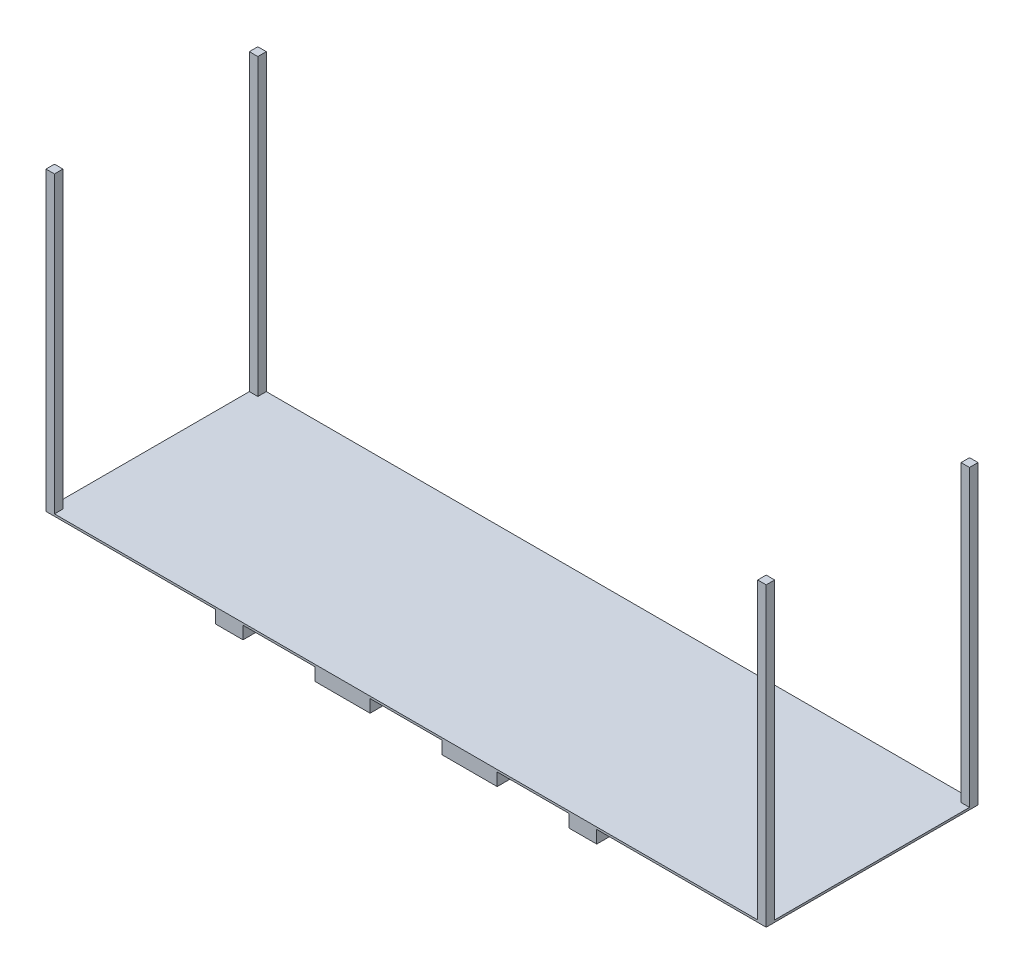
from build123d import *

# Parameters (mm, degrees)
SKETCH1_W           = 1700
SKETCH1_H           = 500
BOSS_EXTRUDE1_DEPTH = 5
SKETCH2_W           = 20
SKETCH2_H           = 20
BOSS_EXTRUDE2_DEPTH = 695
SKETCH3_W           = 900
SKETCH3_H           = 500
BOSS_EXTRUDE3_DEPTH = 30
SKETCH4_W           = 170
SKETCH4_H           = 500
CUT_EXTRUDE1_DEPTH  = 30


with BuildPart() as part:
    # Sketch1 → Boss-Extrude1 (new body)
    with BuildSketch(Plane(origin=(0, 0, 0), x_dir=(1, 0, 0), z_dir=(0, 1, 0))):
        with Locations((850, 250)):
            Rectangle(SKETCH1_W, SKETCH1_H)
    extrude(amount=BOSS_EXTRUDE1_DEPTH)

    # Sketch2 → Boss-Extrude2 (add)
    with BuildSketch(Plane(origin=(0, 5, 0), x_dir=(1, 0, 0), z_dir=(0, 1, 0))):
        with Locations((10, 490)):
            Rectangle(SKETCH2_W, SKETCH2_H)
        with Locations((10, 10)):
            Rectangle(SKETCH2_W, SKETCH2_H)
        with Locations((1690, 10)):
            Rectangle(SKETCH2_W, SKETCH2_H)
        with Locations((1690, 490)):
            Rectangle(SKETCH2_W, SKETCH2_H)
    extrude(amount=BOSS_EXTRUDE2_DEPTH)

    # Sketch3 → Boss-Extrude3 (add)
    with BuildSketch(Plane.XZ):
        with Locations((850, -250)):
            Rectangle(SKETCH3_W, SKETCH3_H)
    extrude(amount=BOSS_EXTRUDE3_DEPTH)

    # Sketch4 → Cut-Extrude1 (cut)
    with BuildSketch(Plane.XZ.offset(30)):
        with Locations((550, -250)):
            Rectangle(SKETCH4_W, SKETCH4_H)
        with Locations((850, -250)):
            Rectangle(SKETCH4_W, SKETCH4_H)
        with Locations((1150, -250)):
            Rectangle(SKETCH4_W, SKETCH4_H)
    extrude(amount=-CUT_EXTRUDE1_DEPTH, mode=Mode.SUBTRACT)


solid = part.part
